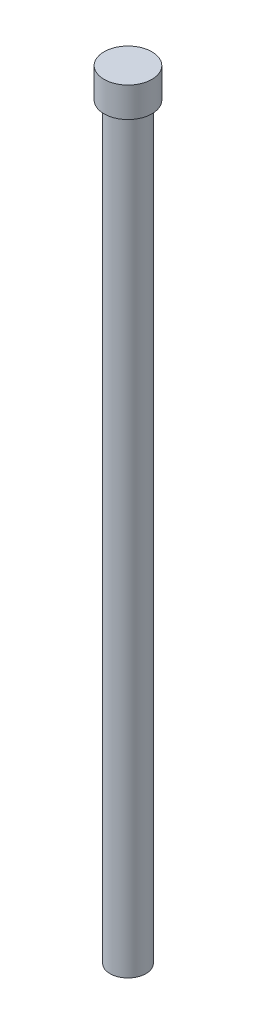
from build123d import *

# Parameters (mm, degrees)
SKETCH1_R           = 0.762
BOSS_EXTRUDE1_DEPTH = 31.75
SKETCH2_R           = 1.016
BOSS_EXTRUDE2_DEPTH = 1.27


with BuildPart() as part:
    # Sketch1 → Boss-Extrude1 (new body)
    with BuildSketch(Plane(origin=(0, 0, 0), x_dir=(1, 0, 0), z_dir=(0, 1, 0))):
        Circle(SKETCH1_R)
    extrude(amount=BOSS_EXTRUDE1_DEPTH)

    # Sketch2 → Boss-Extrude2 (add)
    with BuildSketch(Plane(origin=(0, 31.75, 0), x_dir=(1, 0, 0), z_dir=(0, 1, 0))):
        Circle(SKETCH2_R)
    extrude(amount=BOSS_EXTRUDE2_DEPTH)


solid = part.part
